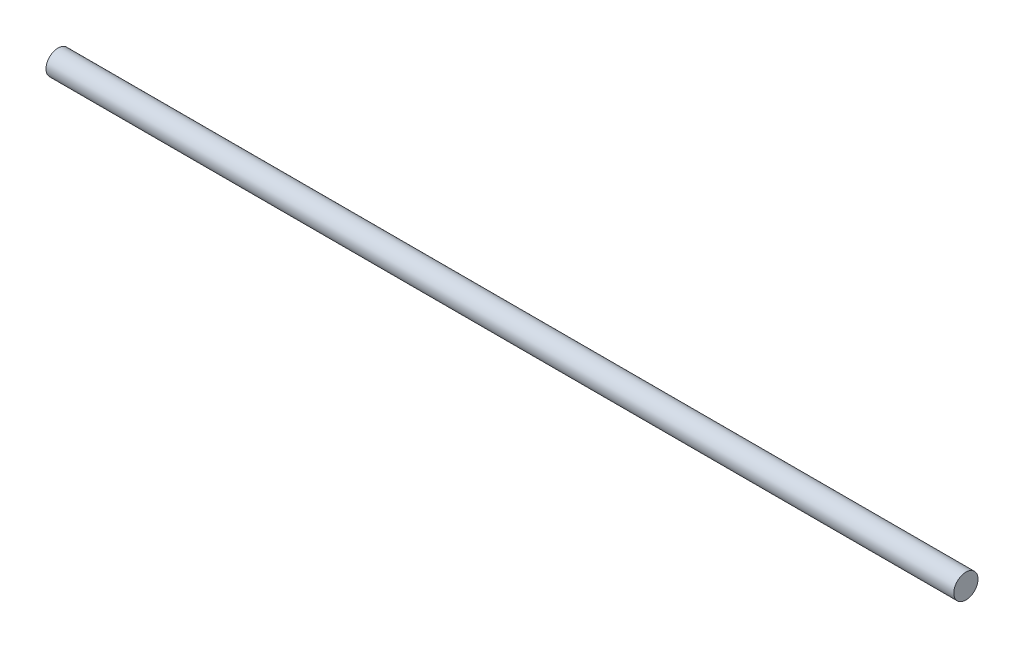
from build123d import *

# Parameters (mm, degrees)
SKETCH2_R           = 4
BOSS_EXTRUDE1_DEPTH = 300


with BuildPart() as part:
    # Sketch2 → Boss-Extrude1 (new body)
    with BuildSketch(Plane(origin=(0, 0, 0), x_dir=(0, 0, -1), z_dir=(1, 0, 0))):
        Circle(SKETCH2_R)
    extrude(amount=BOSS_EXTRUDE1_DEPTH)


solid = part.part
